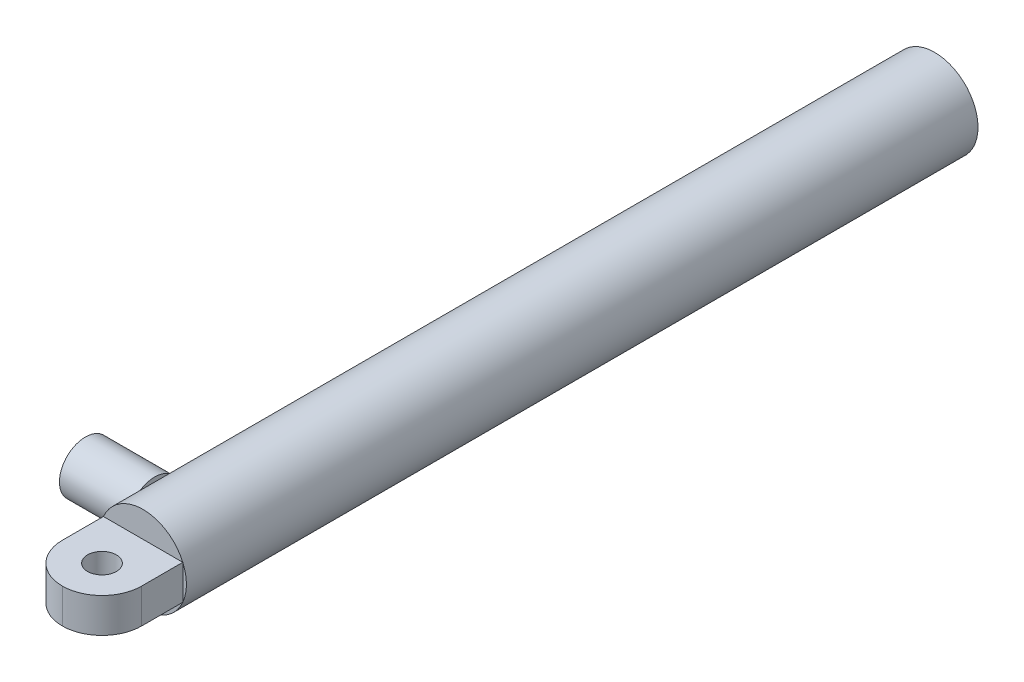
from build123d import *

# Parameters (mm, degrees)
SKETCH1_R           = 37.5
SKETCH1_R_2         = 17.5
BOSS_EXTRUDE1_DEPTH = 664
SKETCH5_R           = 37.5
BOSS_EXTRUDE2_DEPTH = 22
SKETCH8_W           = 68.738635424
SKETCH8_H           = 15
BOSS_EXTRUDE3_DEPTH = 70
FILLET1_R           = 34.36
SKETCH9_R           = 12.5
CUT_EXTRUDE1_DEPTH  = 100
SKETCH10_R          = 22.5
BOSS_EXTRUDE4_DEPTH = 60


with BuildPart() as part:
    # Sketch1 → Boss-Extrude1 (new body)
    with BuildSketch(Plane.XY):
        Circle(SKETCH1_R)
        Circle(SKETCH1_R_2, mode=Mode.SUBTRACT)
    extrude(amount=BOSS_EXTRUDE1_DEPTH)

    # Sketch5 → Boss-Extrude2 (add)
    with BuildSketch(Plane.XY.offset(664)):
        Circle(SKETCH5_R)
    extrude(amount=BOSS_EXTRUDE2_DEPTH)

    # Sketch8 → Boss-Extrude3 (add)
    with BuildSketch(Plane.XY.offset(686)):
        with Locations((0, -7.5)):
            Rectangle(SKETCH8_W, SKETCH8_H)
    boss_extrude3 = extrude(amount=BOSS_EXTRUDE3_DEPTH)

    # Mirror1: Boss-Extrude3 across plane
    add(boss_extrude3.mirror(Plane(origin=(-34.369317712, 0, 756), x_dir=(0, 0, 1), z_dir=(0, -1, 0))))

    # Fillet1
    fillet1_edges = [part.edges().sort_by_distance(p)[0] for p in [
        (-34.369317712, 0, 756),
        (34.369317712, 0, 756),
    ]]
    fillet(fillet1_edges, radius=FILLET1_R)

    # Sketch9 → Cut-Extrude1 (cut, symmetric)
    with BuildSketch(Plane(origin=(0, 15, 0), x_dir=(1, 0, 0), z_dir=(0, 1, 0))):
        with Locations((0, -721.64)):
            Circle(SKETCH9_R)
    extrude(amount=CUT_EXTRUDE1_DEPTH, both=True, mode=Mode.SUBTRACT)

    # Sketch10 → Boss-Extrude4 (add)
    with BuildSketch(Plane.ZY.offset(34.369317712)):
        with Locations((641.64, 0)):
            Circle(SKETCH10_R)
    extrude(amount=BOSS_EXTRUDE4_DEPTH)


solid = part.part
